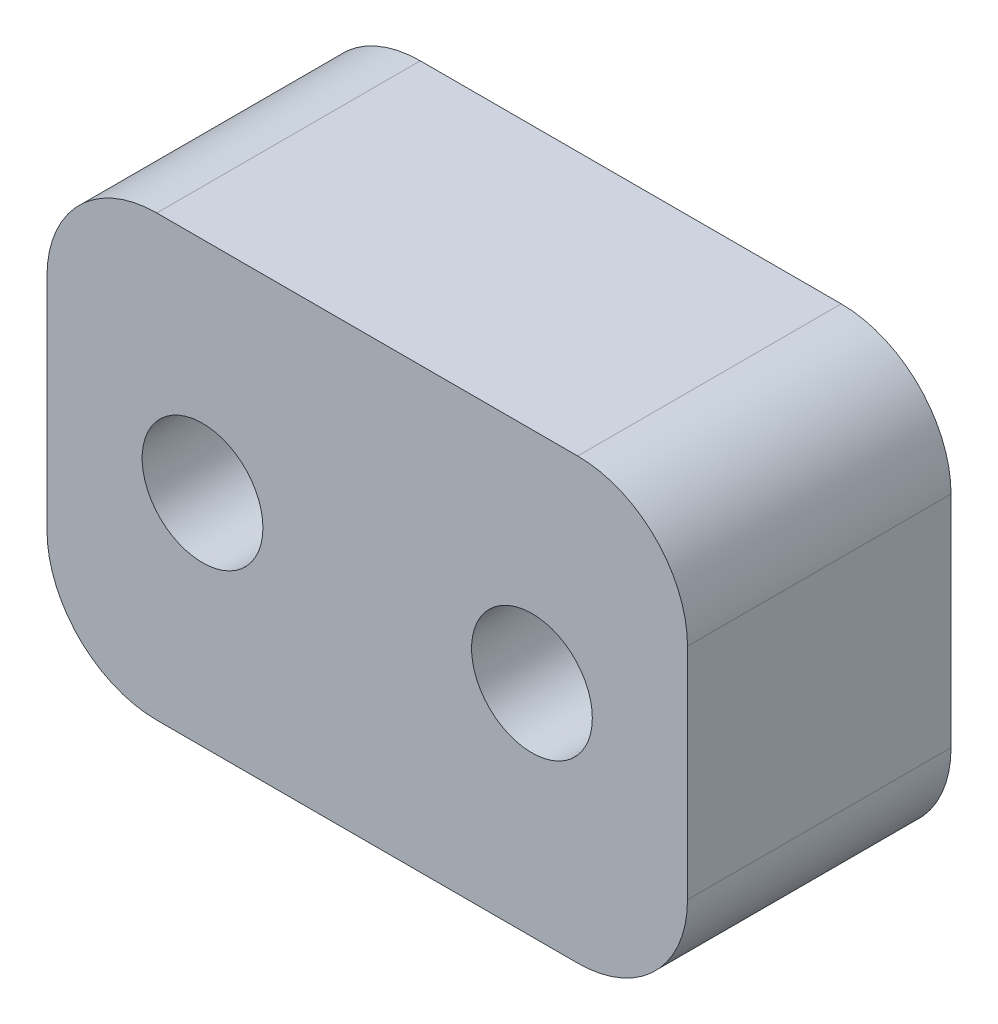
from build123d import *

# Parameters (mm, degrees)
SKETCH1_W           = 17.5
SKETCH1_H           = 12
BOSS_EXTRUDE1_DEPTH = 7.2
FILLET1_R           = 3
SKETCH2_R           = 1.65
CUT_EXTRUDE1_DEPTH  = 8.2


with BuildPart() as part:
    # Sketch1 → Boss-Extrude1 (new body)
    with BuildSketch(Plane.XY):
        Rectangle(SKETCH1_W, SKETCH1_H)
    extrude(amount=BOSS_EXTRUDE1_DEPTH)

    # Fillet1
    fillet1_edges = [part.edges().sort_by_distance(p)[0] for p in [
        (-8.75, 6, 3.6),
        (8.75, 6, 3.6),
        (8.75, -6, 3.6),
        (-8.75, -6, 3.6),
    ]]
    fillet(fillet1_edges, radius=FILLET1_R)

    # Sketch2 → Cut-Extrude1 (cut, through all)
    with BuildSketch(Plane.XY.offset(7.2)):
        with Locations((-4.5, 0)):
            Circle(SKETCH2_R)
        with Locations((4.5, 0)):
            Circle(SKETCH2_R)
    extrude(amount=-CUT_EXTRUDE1_DEPTH, mode=Mode.SUBTRACT)


solid = part.part
